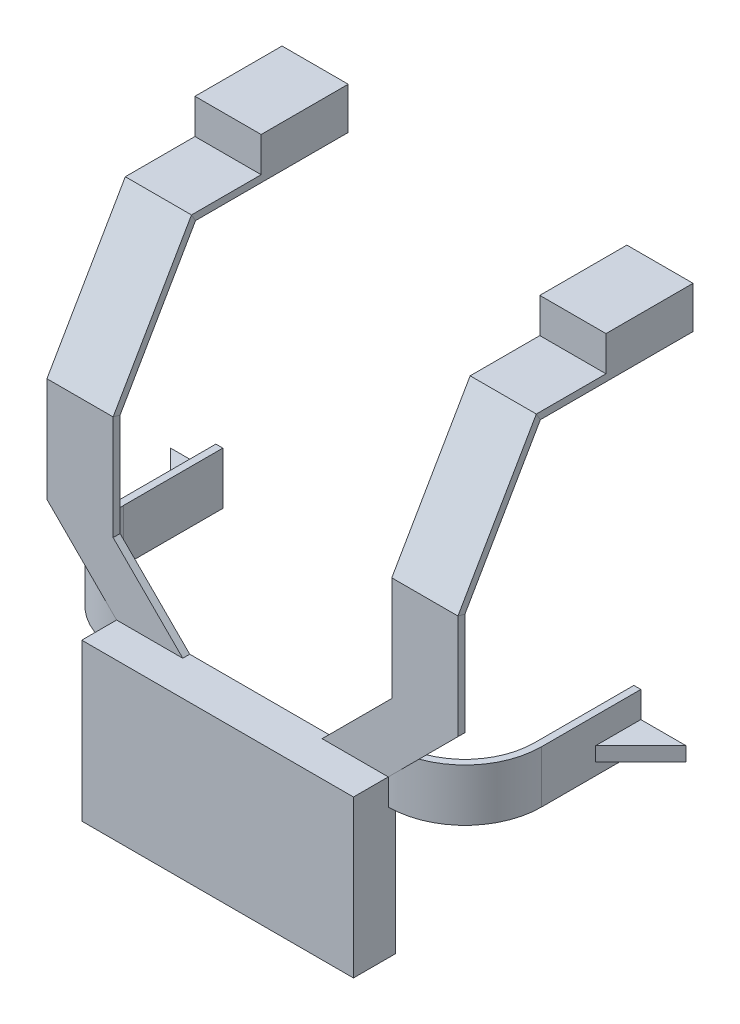
from build123d import *

# Parameters (mm, degrees)
EXTRUDE_1_DEPTH     = 4
SKETCH_11_W         = 156
SKETCH_11_H         = 90
EXTRUDE_2_DEPTH     = 20
SKETCH_12_W         = 38
SKETCH_12_H         = 4
SKETCH_14_W         = 38
SKETCH_14_H         = 50
EXTRUDE_3_DEPTH     = 20
SKETCH_16_W         = 238.183586275
SKETCH_16_H         = 132.295328182
CUT_EXTRUDE_1_DEPTH = 10
SKETCH_17_W         = 40
SKETCH_17_H         = 20
EXTRUDE_4_DEPTH     = 4
SKETCH_21_R         = 6
SKETCH_21_R_2       = 4
EXTRUDE_8_DEPTH     = 4
EXTRUDE_11_DEPTH    = 15
EXTRUDE_12_DEPTH    = 8


with BuildPart() as part:
    # 草图1 → 凸台-拉伸1 (new body)
    with BuildSketch(Plane.XY):
        Polygon((-40, 0), (40, 0), (40, -160), (78, -160), (78, 0), (78, 50), (118, 90), (80, 90), (40, 50), (-40, 50), (-80, 90), (-118, 90), (-78, 50), (-78, 0), (-78, -160), (-40, -160), align=None)
    extrude(amount=EXTRUDE_1_DEPTH)

    # 草图11 → 凸台-拉伸2 (add)
    with BuildSketch(Plane.XY.offset(4)):
        with Locations((0, 5)):
            Rectangle(SKETCH_11_W, SKETCH_11_H)
    extrude(amount=EXTRUDE_2_DEPTH)

    # 扫描1: sweep along a path in 草图13
    with BuildLine(Plane(origin=(78, 0, 0), x_dir=(0, 0, -1), z_dir=(1, 0, 0))) as sweep_1_path:
        Line((-4, 90), (-4, 150))
        Line((-4, 150), (41, 227.942286341))
        Line((41, 227.942286341), (131, 227.942286341))
    # 草图12 → 扫描1 (sweep)
    with BuildSketch(Plane(origin=(0, 90, 0), x_dir=(1, 0, 0), z_dir=(0, 1, 0))):
        with Locations((-99, -2)):
            Rectangle(SKETCH_12_W, SKETCH_12_H)
        with Locations((99, -2)):
            Rectangle(SKETCH_12_W, SKETCH_12_H)
    sweep(path=sweep_1_path.line, transition=Transition.RIGHT)

    # 草图14 → 凸台-拉伸3 (add)
    with BuildSketch(Plane(origin=(0, 227.942286341, 0), x_dir=(1, 0, 0), z_dir=(0, 1, 0))):
        with Locations((-99, 106)):
            Rectangle(SKETCH_14_W, SKETCH_14_H)
        with Locations((99, 106)):
            Rectangle(SKETCH_14_W, SKETCH_14_H)
    extrude(amount=EXTRUDE_3_DEPTH)

    # 草图16 → 切除-拉伸1 (cut)
    with BuildSketch(Plane(origin=(0, 0, 0), x_dir=(-1, 0, 0), z_dir=(0, 0, -1))):
        with Locations((8.714033644, -106.147664091)):
            Rectangle(SKETCH_16_W, SKETCH_16_H)
    extrude(amount=-CUT_EXTRUDE_1_DEPTH, mode=Mode.SUBTRACT)

    # 草图17 → 凸台-拉伸4 (add)
    with BuildSketch(Plane.XZ.offset(40)):
        with Locations((0, 10)):
            Rectangle(SKETCH_17_W, SKETCH_17_H)
    extrude(amount=EXTRUDE_4_DEPTH)

    # 草图21 → 凸台-拉伸8 (add)
    with BuildSketch(Plane.XZ.offset(44)):
        with Locations((0, 9.5)):
            Circle(SKETCH_21_R)
        with Locations((0, 9.5)):
            Circle(SKETCH_21_R_2, mode=Mode.SUBTRACT)
    extrude(amount=EXTRUDE_8_DEPTH)

    # 草图28 → 凸台-拉伸11 (add, symmetric)
    with BuildSketch(Plane(origin=(0, 50, 0), x_dir=(1, 0, 0), z_dir=(0, 1, 0))):
        with BuildLine():
            Line((-122, 40), (-122, 97))
            Line((-122, 97), (-118, 97))
            Line((-118, 97), (-118, 40))
            ThreePointArc((-118, 40), (-106.284271247, 11.715728753), (-78, 0))
            Line((-78, 0), (-78, -4))
            ThreePointArc((-78, -4), (-109.112698372, 8.887301628), (-122, 40))
        make_face()
        with BuildLine():
            Line((118, 40), (118, 97))
            Line((118, 97), (122, 97))
            Line((122, 97), (122, 40))
            ThreePointArc((122, 40), (109.112698372, 8.887301628), (78, -4))
            Line((78, -4), (78, 0))
            ThreePointArc((78, 0), (106.284271247, 11.715728753), (118, 40))
        make_face()
    extrude(amount=EXTRUDE_11_DEPTH, both=True)

    # 草图29 → 凸台-拉伸12 (add)
    with BuildSketch(Plane(origin=(0, 50, 0), x_dir=(1, 0, 0), z_dir=(0, 1, 0))):
        Polygon((122, 97), (148, 97), (122, 71), align=None)
        Polygon((-122, 97), (-148, 97), (-122, 71), align=None)
    extrude(amount=-EXTRUDE_12_DEPTH)


solid = part.part
